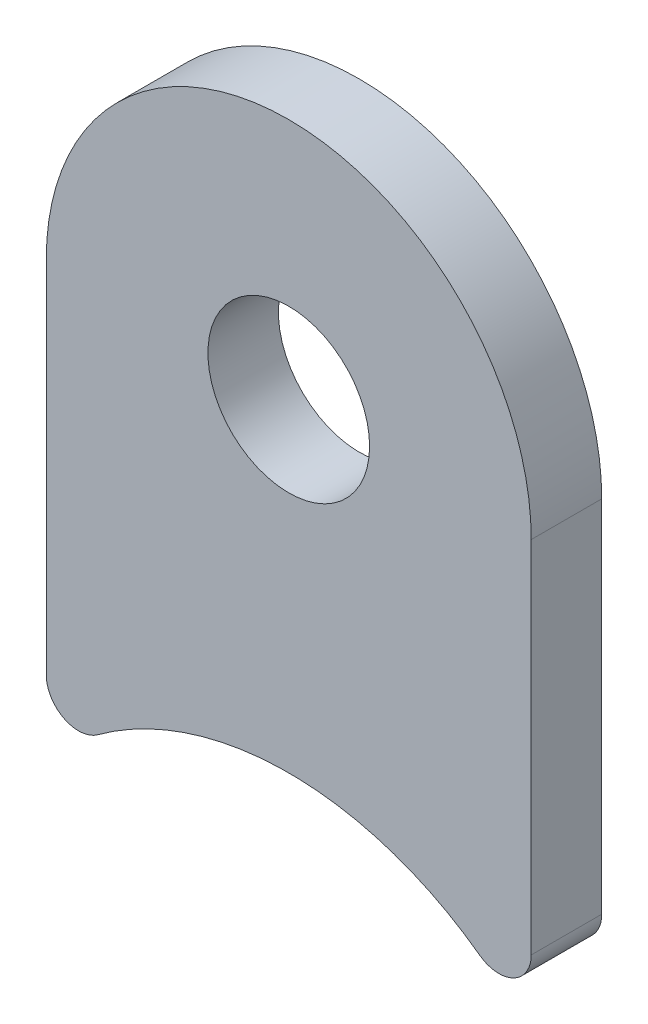
from build123d import *

# Parameters (mm, degrees)
SKETCH1_R           = 3.175
BOSS_EXTRUDE1_DEPTH = 1.3843


with BuildPart() as part:
    # Sketch1 → Boss-Extrude1 (new body, symmetric)
    with BuildSketch(Plane.XY):
        with BuildLine():
            Line((9.525, 11.270131987), (9.525, 25.4))
            ThreePointArc((9.525, 25.4), (0, 34.925), (-9.525, 25.4))
            Line((-9.525, 25.4), (-9.525, 11.270131987))
            ThreePointArc((-9.525, 11.270131987), (-8.829379111, 10.137441104), (-7.504545455, 10.245574533))
            ThreePointArc((-7.504545455, 10.245574533), (0, 12.7), (7.504545455, 10.245574533))
            ThreePointArc((7.504545455, 10.245574533), (8.829379111, 10.137441104), (9.525, 11.270131987))
        make_face()
        with Locations((0, 25.4)):
            Circle(SKETCH1_R, mode=Mode.SUBTRACT)
    extrude(amount=BOSS_EXTRUDE1_DEPTH, both=True)


solid = part.part
